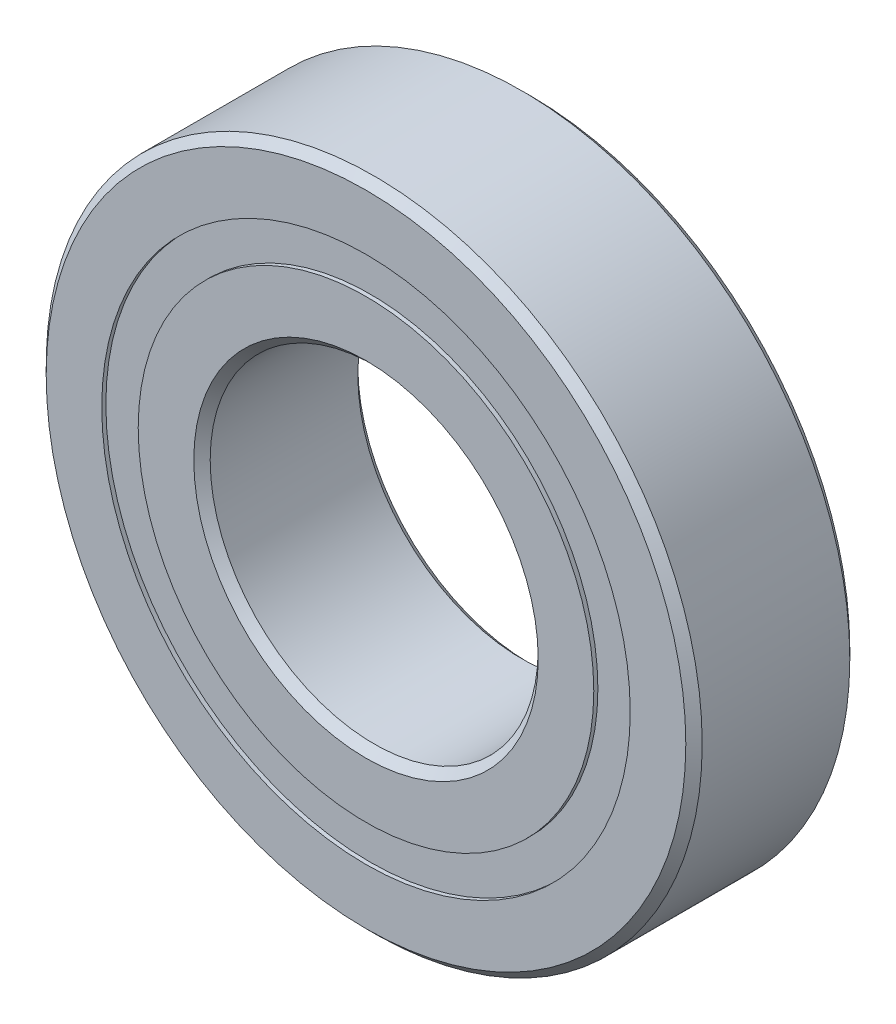
from build123d import *

# Parameters (mm, degrees)
CIRPATTERN1_COUNT = 18
SKETCH5_W         = 0.90619201
SKETCH5_H         = 0.888888888


with BuildPart() as part:
    # Sketch1 → Revolve1 (revolve)
    with BuildSketch(Plane(origin=(0, 0, 0), x_dir=(0, 0, -1), z_dir=(1, 0, 0))):
        with BuildLine():
            Line((1.8, 8), (-1.8, 8))
            Line((-1.8, 8), (-2, 7.8))
            Line((-2, 7.8), (-2, 6.444444444))
            Line((-2, 6.444444444), (-0.888888889, 6.444444444))
            ThreePointArc((-0.888888889, 6.444444444), (0, 6.99380799), (0.888888889, 6.444444444))
            Line((0.888888889, 6.444444444), (2, 6.444444444))
            Line((2, 6.444444444), (2, 7.8))
            Line((2, 7.8), (1.8, 8))
        make_face()
    revolve(axis=Axis((0, 0, 2), (0, 0, -1)))


with BuildPart() as body_2:
    # Sketch2 → Revolve2 (revolve)
    with BuildSketch(Plane(origin=(0, 0, 0), x_dir=(0, 0, -1), z_dir=(1, 0, 0))):
        with BuildLine():
            Line((-2, 5.555555556), (-0.888888889, 5.555555556))
            ThreePointArc((-0.888888889, 5.555555556), (0, 5.00619201), (0.888888889, 5.555555556))
            Line((0.888888889, 5.555555556), (2, 5.555555556))
            Line((2, 5.555555556), (2, 4.2))
            Line((2, 4.2), (1.8, 4))
            Line((1.8, 4), (-1.8, 4))
            Line((-1.8, 4), (-2, 4.2))
            Line((-2, 4.2), (-2, 5.555555556))
        make_face()
    revolve(axis=Axis((0, 0, 2), (0, 0, -1)))


with BuildPart() as body_3:
    # Sketch3 → Revolve3 (revolve)
    with BuildSketch(Plane(origin=(0, 0, 0), x_dir=(0, 0, -1), z_dir=(1, 0, 0))):
        with BuildLine():
            Line((-0.99380799, 6), (0.99380799, 6))
            ThreePointArc((0.99380799, 6), (0, 6.99380799), (-0.99380799, 6))
        make_face()
    revolve(axis=Axis((0, 6, 0.99380799), (0, 0, -1)))


with BuildPart() as cirpattern1_1:
    # CirPattern1: pattern copy
    add(body_3.part.rotate(Axis((0, 0, -2), (0, 0, 1)), 1 * 360 / CIRPATTERN1_COUNT))


with BuildPart() as cirpattern1_2:
    # CirPattern1: pattern copy
    add(body_3.part.rotate(Axis((0, 0, -2), (0, 0, 1)), 2 * 360 / CIRPATTERN1_COUNT))


with BuildPart() as cirpattern1_3:
    # CirPattern1: pattern copy
    add(body_3.part.rotate(Axis((0, 0, -2), (0, 0, 1)), 3 * 360 / CIRPATTERN1_COUNT))


with BuildPart() as cirpattern1_4:
    # CirPattern1: pattern copy
    add(body_3.part.rotate(Axis((0, 0, -2), (0, 0, 1)), 4 * 360 / CIRPATTERN1_COUNT))


with BuildPart() as cirpattern1_5:
    # CirPattern1: pattern copy
    add(body_3.part.rotate(Axis((0, 0, -2), (0, 0, 1)), 5 * 360 / CIRPATTERN1_COUNT))


with BuildPart() as cirpattern1_6:
    # CirPattern1: pattern copy
    add(body_3.part.rotate(Axis((0, 0, -2), (0, 0, 1)), 6 * 360 / CIRPATTERN1_COUNT))


with BuildPart() as cirpattern1_7:
    # CirPattern1: pattern copy
    add(body_3.part.rotate(Axis((0, 0, -2), (0, 0, 1)), 7 * 360 / CIRPATTERN1_COUNT))


with BuildPart() as cirpattern1_8:
    # CirPattern1: pattern copy
    add(body_3.part.rotate(Axis((0, 0, -2), (0, 0, 1)), 8 * 360 / CIRPATTERN1_COUNT))


with BuildPart() as cirpattern1_9:
    # CirPattern1: pattern copy
    add(body_3.part.rotate(Axis((0, 0, -2), (0, 0, 1)), 9 * 360 / CIRPATTERN1_COUNT))


with BuildPart() as cirpattern1_10:
    # CirPattern1: pattern copy
    add(body_3.part.rotate(Axis((0, 0, -2), (0, 0, 1)), 10 * 360 / CIRPATTERN1_COUNT))


with BuildPart() as cirpattern1_11:
    # CirPattern1: pattern copy
    add(body_3.part.rotate(Axis((0, 0, -2), (0, 0, 1)), 11 * 360 / CIRPATTERN1_COUNT))


with BuildPart() as cirpattern1_12:
    # CirPattern1: pattern copy
    add(body_3.part.rotate(Axis((0, 0, -2), (0, 0, 1)), 12 * 360 / CIRPATTERN1_COUNT))


with BuildPart() as cirpattern1_13:
    # CirPattern1: pattern copy
    add(body_3.part.rotate(Axis((0, 0, -2), (0, 0, 1)), 13 * 360 / CIRPATTERN1_COUNT))


with BuildPart() as cirpattern1_14:
    # CirPattern1: pattern copy
    add(body_3.part.rotate(Axis((0, 0, -2), (0, 0, 1)), 14 * 360 / CIRPATTERN1_COUNT))


with BuildPart() as cirpattern1_15:
    # CirPattern1: pattern copy
    add(body_3.part.rotate(Axis((0, 0, -2), (0, 0, 1)), 15 * 360 / CIRPATTERN1_COUNT))


with BuildPart() as cirpattern1_16:
    # CirPattern1: pattern copy
    add(body_3.part.rotate(Axis((0, 0, -2), (0, 0, 1)), 16 * 360 / CIRPATTERN1_COUNT))


with BuildPart() as cirpattern1_17:
    # CirPattern1: pattern copy
    add(body_3.part.rotate(Axis((0, 0, -2), (0, 0, 1)), 17 * 360 / CIRPATTERN1_COUNT))


with BuildPart() as body_21:
    # Sketch5 → Revolve5 (revolve)
    with BuildSketch(Plane(origin=(0, 0, 0), x_dir=(0, 0, -1), z_dir=(1, 0, 0))):
        with Locations((-1.446903995, 6)):
            Rectangle(SKETCH5_W, SKETCH5_H)
        with Locations((1.446903995, 6)):
            Rectangle(SKETCH5_W, SKETCH5_H)
    revolve(axis=Axis((0, 0, 2), (0, 0, -1)))


solid = Compound([part.part, body_2.part, body_3.part, cirpattern1_1.part, cirpattern1_2.part, cirpattern1_3.part, cirpattern1_4.part, cirpattern1_5.part, cirpattern1_6.part, cirpattern1_7.part, cirpattern1_8.part, cirpattern1_9.part, cirpattern1_10.part, cirpattern1_11.part, cirpattern1_12.part, cirpattern1_13.part, cirpattern1_14.part, cirpattern1_15.part, cirpattern1_16.part, cirpattern1_17.part, body_21.part])
